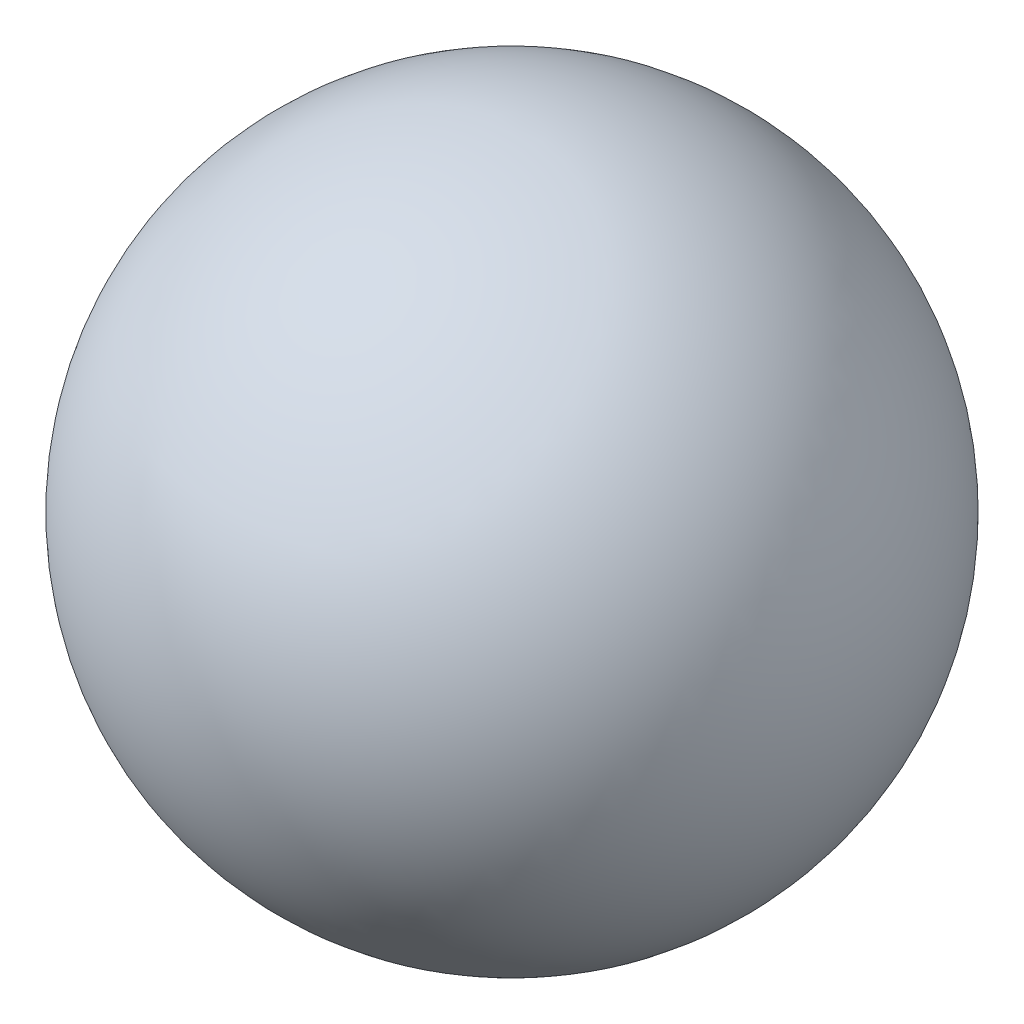
from build123d import *


with BuildPart() as part:
    # Sketch1 → Revolve3 (revolve)
    with BuildSketch(Plane(origin=(0, 0, 0), x_dir=(0, 0, -1), z_dir=(1, 0, 0))):
        with BuildLine():
            Line((0, 10), (0, -10))
            ThreePointArc((0, -10), (-10, 0), (0, 10))
        make_face()
    revolve(axis=Axis((0, 10, 0), (0, -1, 0)))


solid = part.part
